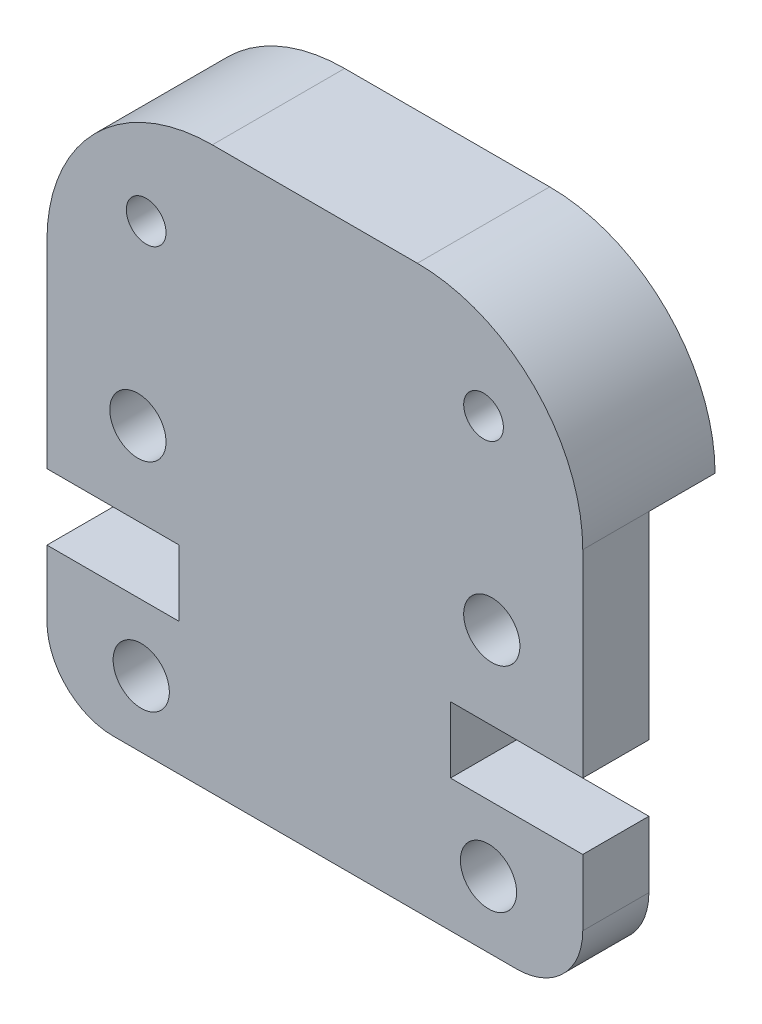
from build123d import *

# Parameters (mm, degrees)
SKETCH1_R           = 0.85
SKETCH1_R_2         = 0.6
BOSS_EXTRUDE1_DEPTH = 4
SKETCH2_W           = 16.2
SKETCH2_H           = 11.98
CUT_EXTRUDE1_DEPTH  = 2


with BuildPart() as part:
    # Sketch1 → Boss-Extrude1 (new body)
    with BuildSketch(Plane.XY):
        with BuildLine():
            Line((3.1, 16.98), (-3.1, 16.98))
            ThreePointArc((-3.1, 16.98), (-6.635533906, 15.515533906), (-8.1, 11.98))
            Line((-8.1, 11.98), (-8.1, 6))
            Line((-8.1, 6), (-4.1, 6))
            Line((-4.1, 6), (-4.1, 4))
            Line((-4.1, 4), (-8.1, 4))
            Line((-8.1, 4), (-8.1, 2))
            ThreePointArc((-8.1, 2), (-7.514213562, 0.585786438), (-6.1, 0))
            Line((-6.1, 0), (6.1, 0))
            ThreePointArc((6.1, 0), (7.514213562, 0.585786438), (8.1, 2))
            Line((8.1, 2), (8.1, 4))
            Line((8.1, 4), (4.1, 4))
            Line((4.1, 4), (4.1, 6))
            Line((4.1, 6), (8.1, 6))
            Line((8.1, 6), (8.1, 11.98))
            ThreePointArc((8.1, 11.98), (6.635533906, 15.515533906), (3.1, 16.98))
        make_face()
        with Locations((-5.25, 2)):
            Circle(SKETCH1_R, mode=Mode.SUBTRACT)
        with Locations((-5.1, 13.98)):
            Circle(SKETCH1_R_2, mode=Mode.SUBTRACT)
        with Locations((-5.35, 8.5)):
            Circle(SKETCH1_R, mode=Mode.SUBTRACT)
        with Locations((5.35, 8.5)):
            Circle(SKETCH1_R, mode=Mode.SUBTRACT)
        with Locations((5.1, 13.98)):
            Circle(SKETCH1_R_2, mode=Mode.SUBTRACT)
        with Locations((5.25, 2)):
            Circle(SKETCH1_R, mode=Mode.SUBTRACT)
    extrude(amount=BOSS_EXTRUDE1_DEPTH)

    # Sketch2 → Cut-Extrude1 (cut)
    with BuildSketch(Plane.XY):
        with Locations((0, 5.99)):
            Rectangle(SKETCH2_W, SKETCH2_H)
    extrude(amount=CUT_EXTRUDE1_DEPTH, mode=Mode.SUBTRACT)


solid = part.part
